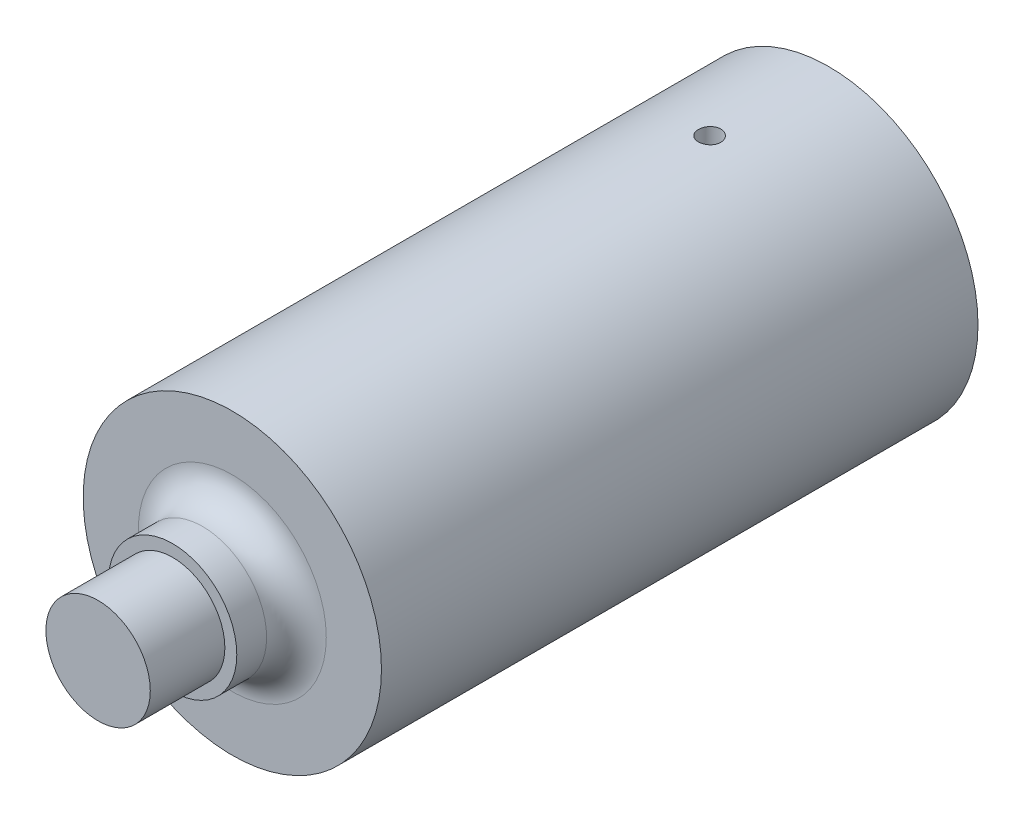
from build123d import *

# Parameters (mm, degrees)
ESQUISSE1_R                  = 10
BOSS_EXTRU_1_DEPTH           = 40
ESQUISSE2_R                  = 0.75
ENL_V_MAT_EXTRU_1_DEPTH      = 40
ENL_V_MAT_EXTRU_1_DEPTH_BACK = 40
ESQUISSE3_R                  = 5.241374435
BOSS_EXTRU_2_DEPTH           = 20
ESQUISSE4_R                  = 3.5
BOSS_EXTRU_3_DEPTH           = 9
ESQUISSE5_R                  = 4.3
BOSS_EXTRU_4_DEPTH           = 4
CONG_2_R                     = 2


with BuildPart() as part:
    # Esquisse1 → Boss.-Extru.1 (new body)
    with BuildSketch(Plane.XY):
        Circle(ESQUISSE1_R)
        Polygon((4.156921938, 0), (2.078460969, 3.6), (-2.078460969, 3.6), (-4.156921938, 0), (-2.078460969, -3.6), (2.078460969, -3.6), align=None, mode=Mode.SUBTRACT)
    extrude(amount=BOSS_EXTRU_1_DEPTH)

    # Esquisse2 → Enlèv. mat.-Extru.1 (cut, two sides)
    with BuildSketch(Plane(origin=(0, 0, 0), x_dir=(1, 0, 0), z_dir=(0, 1, 0))) as enl_v_mat_extru_1_sk:
        with Locations((0, -8)):
            Circle(ESQUISSE2_R)
    extrude(amount=ENL_V_MAT_EXTRU_1_DEPTH, mode=Mode.SUBTRACT)
    extrude(enl_v_mat_extru_1_sk.sketch, amount=-ENL_V_MAT_EXTRU_1_DEPTH_BACK, mode=Mode.SUBTRACT)

    # Esquisse3 → Boss.-Extru.2 (add)
    with BuildSketch(Plane.XY.offset(40)):
        Circle(ESQUISSE3_R)
    extrude(amount=-BOSS_EXTRU_2_DEPTH)

    # Esquisse4 → Boss.-Extru.3 (add)
    with BuildSketch(Plane.XY.offset(40)):
        Circle(ESQUISSE4_R)
    extrude(amount=BOSS_EXTRU_3_DEPTH)

    # Esquisse5 → Boss.-Extru.4 (add)
    with BuildSketch(Plane.XY.offset(40)):
        Circle(ESQUISSE5_R)
    extrude(amount=BOSS_EXTRU_4_DEPTH)

    # Congé2
    cong_2_edges = [part.edges().sort_by_distance(p)[0] for p in [
        (-4.3, 0, 40),
    ]]
    fillet(cong_2_edges, radius=CONG_2_R)


solid = part.part
